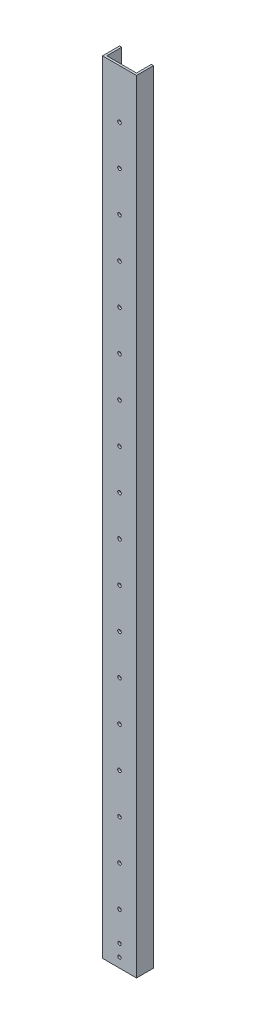
from build123d import *

# Parameters (mm, degrees)
BOSS_EXTRUDE1_DEPTH = 1168.4
CUT_EXTRUDE1_REACH  = 27.4
SKETCH2_R           = 2.667
CUT_EXTRUDE2_REACH  = 27.4
SKETCH3_R           = 2.5527
CUT_EXTRUDE3_REACH  = 52.8
SKETCH4_R           = 2.667


with BuildPart() as part:
    # Sketch1 → Boss-Extrude1 (new body)
    with BuildSketch(Plane(origin=(0, 0, 0), x_dir=(1, 0, 0), z_dir=(0, 1, 0))):
        Polygon((3.175, 3.175), (3.175, 25.4), (0, 25.4), (0, 0), (50.8, 0), (50.8, 25.4), (47.625, 25.4), (47.625, 3.175), align=None)
    extrude(amount=BOSS_EXTRUDE1_DEPTH)

    # Sketch2 → Cut-Extrude1 (cut, up to next)
    with BuildSketch(Plane.XY, mode=Mode.PRIVATE) as cut_extrude1_sk1:
        with Locations((25.4, 76.2)):
            Circle(SKETCH2_R)
    cut_extrude1_tool1 = extrude(cut_extrude1_sk1.sketch, amount=-CUT_EXTRUDE1_REACH, mode=Mode.PRIVATE) & part.part
    add(cut_extrude1_tool1.solids().sort_by_distance((25.4, 76.2, 0))[0], mode=Mode.SUBTRACT)
    # Sketch2 → Cut-Extrude1 (cut, up to next)
    with BuildSketch(Plane.XY, mode=Mode.PRIVATE) as cut_extrude1_sk2:
        with Locations((25.4, 136.144)):
            Circle(SKETCH2_R)
    cut_extrude1_tool2 = extrude(cut_extrude1_sk2.sketch, amount=-CUT_EXTRUDE1_REACH, mode=Mode.PRIVATE) & part.part
    add(cut_extrude1_tool2.solids().sort_by_distance((25.4, 136.144, 0))[0], mode=Mode.SUBTRACT)
    # Sketch2 → Cut-Extrude1 (cut, up to next)
    with BuildSketch(Plane.XY, mode=Mode.PRIVATE) as cut_extrude1_sk3:
        with Locations((25.4, 196.088)):
            Circle(SKETCH2_R)
    cut_extrude1_tool3 = extrude(cut_extrude1_sk3.sketch, amount=-CUT_EXTRUDE1_REACH, mode=Mode.PRIVATE) & part.part
    add(cut_extrude1_tool3.solids().sort_by_distance((25.4, 196.088, 0))[0], mode=Mode.SUBTRACT)
    # Sketch2 → Cut-Extrude1 (cut, up to next)
    with BuildSketch(Plane.XY, mode=Mode.PRIVATE) as cut_extrude1_sk4:
        with Locations((25.4, 256.032)):
            Circle(SKETCH2_R)
    cut_extrude1_tool4 = extrude(cut_extrude1_sk4.sketch, amount=-CUT_EXTRUDE1_REACH, mode=Mode.PRIVATE) & part.part
    add(cut_extrude1_tool4.solids().sort_by_distance((25.4, 256.032, 0))[0], mode=Mode.SUBTRACT)
    # Sketch2 → Cut-Extrude1 (cut, up to next)
    with BuildSketch(Plane.XY, mode=Mode.PRIVATE) as cut_extrude1_sk5:
        with Locations((25.4, 315.976)):
            Circle(SKETCH2_R)
    cut_extrude1_tool5 = extrude(cut_extrude1_sk5.sketch, amount=-CUT_EXTRUDE1_REACH, mode=Mode.PRIVATE) & part.part
    add(cut_extrude1_tool5.solids().sort_by_distance((25.4, 315.976, 0))[0], mode=Mode.SUBTRACT)
    # Sketch2 → Cut-Extrude1 (cut, up to next)
    with BuildSketch(Plane.XY, mode=Mode.PRIVATE) as cut_extrude1_sk6:
        with Locations((25.4, 375.92)):
            Circle(SKETCH2_R)
    cut_extrude1_tool6 = extrude(cut_extrude1_sk6.sketch, amount=-CUT_EXTRUDE1_REACH, mode=Mode.PRIVATE) & part.part
    add(cut_extrude1_tool6.solids().sort_by_distance((25.4, 375.92, 0))[0], mode=Mode.SUBTRACT)
    # Sketch2 → Cut-Extrude1 (cut, up to next)
    with BuildSketch(Plane.XY, mode=Mode.PRIVATE) as cut_extrude1_sk7:
        with Locations((25.4, 435.864)):
            Circle(SKETCH2_R)
    cut_extrude1_tool7 = extrude(cut_extrude1_sk7.sketch, amount=-CUT_EXTRUDE1_REACH, mode=Mode.PRIVATE) & part.part
    add(cut_extrude1_tool7.solids().sort_by_distance((25.4, 435.864, 0))[0], mode=Mode.SUBTRACT)
    # Sketch2 → Cut-Extrude1 (cut, up to next)
    with BuildSketch(Plane.XY, mode=Mode.PRIVATE) as cut_extrude1_sk8:
        with Locations((25.4, 495.808)):
            Circle(SKETCH2_R)
    cut_extrude1_tool8 = extrude(cut_extrude1_sk8.sketch, amount=-CUT_EXTRUDE1_REACH, mode=Mode.PRIVATE) & part.part
    add(cut_extrude1_tool8.solids().sort_by_distance((25.4, 495.808, 0))[0], mode=Mode.SUBTRACT)
    # Sketch2 → Cut-Extrude1 (cut, up to next)
    with BuildSketch(Plane.XY, mode=Mode.PRIVATE) as cut_extrude1_sk9:
        with Locations((25.4, 555.752)):
            Circle(SKETCH2_R)
    cut_extrude1_tool9 = extrude(cut_extrude1_sk9.sketch, amount=-CUT_EXTRUDE1_REACH, mode=Mode.PRIVATE) & part.part
    add(cut_extrude1_tool9.solids().sort_by_distance((25.4, 555.752, 0))[0], mode=Mode.SUBTRACT)
    # Sketch2 → Cut-Extrude1 (cut, up to next)
    with BuildSketch(Plane.XY, mode=Mode.PRIVATE) as cut_extrude1_sk10:
        with Locations((25.4, 615.696)):
            Circle(SKETCH2_R)
    cut_extrude1_tool10 = extrude(cut_extrude1_sk10.sketch, amount=-CUT_EXTRUDE1_REACH, mode=Mode.PRIVATE) & part.part
    add(cut_extrude1_tool10.solids().sort_by_distance((25.4, 615.696, 0))[0], mode=Mode.SUBTRACT)
    # Sketch2 → Cut-Extrude1 (cut, up to next)
    with BuildSketch(Plane.XY, mode=Mode.PRIVATE) as cut_extrude1_sk11:
        with Locations((25.4, 675.64)):
            Circle(SKETCH2_R)
    cut_extrude1_tool11 = extrude(cut_extrude1_sk11.sketch, amount=-CUT_EXTRUDE1_REACH, mode=Mode.PRIVATE) & part.part
    add(cut_extrude1_tool11.solids().sort_by_distance((25.4, 675.64, 0))[0], mode=Mode.SUBTRACT)
    # Sketch2 → Cut-Extrude1 (cut, up to next)
    with BuildSketch(Plane.XY, mode=Mode.PRIVATE) as cut_extrude1_sk12:
        with Locations((25.4, 735.584)):
            Circle(SKETCH2_R)
    cut_extrude1_tool12 = extrude(cut_extrude1_sk12.sketch, amount=-CUT_EXTRUDE1_REACH, mode=Mode.PRIVATE) & part.part
    add(cut_extrude1_tool12.solids().sort_by_distance((25.4, 735.584, 0))[0], mode=Mode.SUBTRACT)
    # Sketch2 → Cut-Extrude1 (cut, up to next)
    with BuildSketch(Plane.XY, mode=Mode.PRIVATE) as cut_extrude1_sk13:
        with Locations((25.4, 795.528)):
            Circle(SKETCH2_R)
    cut_extrude1_tool13 = extrude(cut_extrude1_sk13.sketch, amount=-CUT_EXTRUDE1_REACH, mode=Mode.PRIVATE) & part.part
    add(cut_extrude1_tool13.solids().sort_by_distance((25.4, 795.528, 0))[0], mode=Mode.SUBTRACT)
    # Sketch2 → Cut-Extrude1 (cut, up to next)
    with BuildSketch(Plane.XY, mode=Mode.PRIVATE) as cut_extrude1_sk14:
        with Locations((25.4, 855.472)):
            Circle(SKETCH2_R)
    cut_extrude1_tool14 = extrude(cut_extrude1_sk14.sketch, amount=-CUT_EXTRUDE1_REACH, mode=Mode.PRIVATE) & part.part
    add(cut_extrude1_tool14.solids().sort_by_distance((25.4, 855.472, 0))[0], mode=Mode.SUBTRACT)
    # Sketch2 → Cut-Extrude1 (cut, up to next)
    with BuildSketch(Plane.XY, mode=Mode.PRIVATE) as cut_extrude1_sk15:
        with Locations((25.4, 915.416)):
            Circle(SKETCH2_R)
    cut_extrude1_tool15 = extrude(cut_extrude1_sk15.sketch, amount=-CUT_EXTRUDE1_REACH, mode=Mode.PRIVATE) & part.part
    add(cut_extrude1_tool15.solids().sort_by_distance((25.4, 915.416, 0))[0], mode=Mode.SUBTRACT)
    # Sketch2 → Cut-Extrude1 (cut, up to next)
    with BuildSketch(Plane.XY, mode=Mode.PRIVATE) as cut_extrude1_sk16:
        with Locations((25.4, 975.36)):
            Circle(SKETCH2_R)
    cut_extrude1_tool16 = extrude(cut_extrude1_sk16.sketch, amount=-CUT_EXTRUDE1_REACH, mode=Mode.PRIVATE) & part.part
    add(cut_extrude1_tool16.solids().sort_by_distance((25.4, 975.36, 0))[0], mode=Mode.SUBTRACT)
    # Sketch2 → Cut-Extrude1 (cut, up to next)
    with BuildSketch(Plane.XY, mode=Mode.PRIVATE) as cut_extrude1_sk17:
        with Locations((25.4, 1035.304)):
            Circle(SKETCH2_R)
    cut_extrude1_tool17 = extrude(cut_extrude1_sk17.sketch, amount=-CUT_EXTRUDE1_REACH, mode=Mode.PRIVATE) & part.part
    add(cut_extrude1_tool17.solids().sort_by_distance((25.4, 1035.304, 0))[0], mode=Mode.SUBTRACT)
    # Sketch2 → Cut-Extrude1 (cut, up to next)
    with BuildSketch(Plane.XY, mode=Mode.PRIVATE) as cut_extrude1_sk18:
        with Locations((25.4, 1095.248)):
            Circle(SKETCH2_R)
    cut_extrude1_tool18 = extrude(cut_extrude1_sk18.sketch, amount=-CUT_EXTRUDE1_REACH, mode=Mode.PRIVATE) & part.part
    add(cut_extrude1_tool18.solids().sort_by_distance((25.4, 1095.248, 0))[0], mode=Mode.SUBTRACT)

    # Sketch3 → Cut-Extrude2 (cut, up to next)
    with BuildSketch(Plane.XY, mode=Mode.PRIVATE) as cut_extrude2_sk1:
        with Locations((25.4, 32.131)):
            Circle(SKETCH3_R)
    cut_extrude2_tool1 = extrude(cut_extrude2_sk1.sketch, amount=-CUT_EXTRUDE2_REACH, mode=Mode.PRIVATE) & part.part
    add(cut_extrude2_tool1.solids().sort_by_distance((25.4, 32.131, 0))[0], mode=Mode.SUBTRACT)
    # Sketch3 → Cut-Extrude2 (cut, up to next)
    with BuildSketch(Plane.XY, mode=Mode.PRIVATE) as cut_extrude2_sk2:
        with Locations((25.4, 14.2875)):
            Circle(SKETCH3_R)
    cut_extrude2_tool2 = extrude(cut_extrude2_sk2.sketch, amount=-CUT_EXTRUDE2_REACH, mode=Mode.PRIVATE) & part.part
    add(cut_extrude2_tool2.solids().sort_by_distance((25.4, 14.2875, 0))[0], mode=Mode.SUBTRACT)

    # Sketch4 → Cut-Extrude3 (cut, up to next)
    with BuildSketch(Plane.ZY, mode=Mode.PRIVATE) as cut_extrude3_sk1:
        with Locations((-19.05, 76.2)):
            Circle(SKETCH4_R)
    cut_extrude3_tool1 = extrude(cut_extrude3_sk1.sketch, amount=-CUT_EXTRUDE3_REACH, mode=Mode.PRIVATE) & part.part
    add(cut_extrude3_tool1.solids().sort_by_distance((0, 76.2, -19.05))[0], mode=Mode.SUBTRACT)
    # Sketch4 → Cut-Extrude3 (cut, up to next)
    with BuildSketch(Plane.ZY, mode=Mode.PRIVATE) as cut_extrude3_sk2:
        with Locations((-19.05, 136.144)):
            Circle(SKETCH4_R)
    cut_extrude3_tool2 = extrude(cut_extrude3_sk2.sketch, amount=-CUT_EXTRUDE3_REACH, mode=Mode.PRIVATE) & part.part
    add(cut_extrude3_tool2.solids().sort_by_distance((0, 136.144, -19.05))[0], mode=Mode.SUBTRACT)
    # Sketch4 → Cut-Extrude3 (cut, up to next)
    with BuildSketch(Plane.ZY, mode=Mode.PRIVATE) as cut_extrude3_sk3:
        with Locations((-19.05, 196.088)):
            Circle(SKETCH4_R)
    cut_extrude3_tool3 = extrude(cut_extrude3_sk3.sketch, amount=-CUT_EXTRUDE3_REACH, mode=Mode.PRIVATE) & part.part
    add(cut_extrude3_tool3.solids().sort_by_distance((0, 196.088, -19.05))[0], mode=Mode.SUBTRACT)
    # Sketch4 → Cut-Extrude3 (cut, up to next)
    with BuildSketch(Plane.ZY, mode=Mode.PRIVATE) as cut_extrude3_sk4:
        with Locations((-19.05, 256.032)):
            Circle(SKETCH4_R)
    cut_extrude3_tool4 = extrude(cut_extrude3_sk4.sketch, amount=-CUT_EXTRUDE3_REACH, mode=Mode.PRIVATE) & part.part
    add(cut_extrude3_tool4.solids().sort_by_distance((0, 256.032, -19.05))[0], mode=Mode.SUBTRACT)
    # Sketch4 → Cut-Extrude3 (cut, up to next)
    with BuildSketch(Plane.ZY, mode=Mode.PRIVATE) as cut_extrude3_sk5:
        with Locations((-19.05, 315.976)):
            Circle(SKETCH4_R)
    cut_extrude3_tool5 = extrude(cut_extrude3_sk5.sketch, amount=-CUT_EXTRUDE3_REACH, mode=Mode.PRIVATE) & part.part
    add(cut_extrude3_tool5.solids().sort_by_distance((0, 315.976, -19.05))[0], mode=Mode.SUBTRACT)
    # Sketch4 → Cut-Extrude3 (cut, up to next)
    with BuildSketch(Plane.ZY, mode=Mode.PRIVATE) as cut_extrude3_sk6:
        with Locations((-19.05, 375.92)):
            Circle(SKETCH4_R)
    cut_extrude3_tool6 = extrude(cut_extrude3_sk6.sketch, amount=-CUT_EXTRUDE3_REACH, mode=Mode.PRIVATE) & part.part
    add(cut_extrude3_tool6.solids().sort_by_distance((0, 375.92, -19.05))[0], mode=Mode.SUBTRACT)
    # Sketch4 → Cut-Extrude3 (cut, up to next)
    with BuildSketch(Plane.ZY, mode=Mode.PRIVATE) as cut_extrude3_sk7:
        with Locations((-19.05, 435.864)):
            Circle(SKETCH4_R)
    cut_extrude3_tool7 = extrude(cut_extrude3_sk7.sketch, amount=-CUT_EXTRUDE3_REACH, mode=Mode.PRIVATE) & part.part
    add(cut_extrude3_tool7.solids().sort_by_distance((0, 435.864, -19.05))[0], mode=Mode.SUBTRACT)
    # Sketch4 → Cut-Extrude3 (cut, up to next)
    with BuildSketch(Plane.ZY, mode=Mode.PRIVATE) as cut_extrude3_sk8:
        with Locations((-19.05, 495.808)):
            Circle(SKETCH4_R)
    cut_extrude3_tool8 = extrude(cut_extrude3_sk8.sketch, amount=-CUT_EXTRUDE3_REACH, mode=Mode.PRIVATE) & part.part
    add(cut_extrude3_tool8.solids().sort_by_distance((0, 495.808, -19.05))[0], mode=Mode.SUBTRACT)
    # Sketch4 → Cut-Extrude3 (cut, up to next)
    with BuildSketch(Plane.ZY, mode=Mode.PRIVATE) as cut_extrude3_sk9:
        with Locations((-19.05, 555.752)):
            Circle(SKETCH4_R)
    cut_extrude3_tool9 = extrude(cut_extrude3_sk9.sketch, amount=-CUT_EXTRUDE3_REACH, mode=Mode.PRIVATE) & part.part
    add(cut_extrude3_tool9.solids().sort_by_distance((0, 555.752, -19.05))[0], mode=Mode.SUBTRACT)
    # Sketch4 → Cut-Extrude3 (cut, up to next)
    with BuildSketch(Plane.ZY, mode=Mode.PRIVATE) as cut_extrude3_sk10:
        with Locations((-19.05, 615.696)):
            Circle(SKETCH4_R)
    cut_extrude3_tool10 = extrude(cut_extrude3_sk10.sketch, amount=-CUT_EXTRUDE3_REACH, mode=Mode.PRIVATE) & part.part
    add(cut_extrude3_tool10.solids().sort_by_distance((0, 615.696, -19.05))[0], mode=Mode.SUBTRACT)
    # Sketch4 → Cut-Extrude3 (cut, up to next)
    with BuildSketch(Plane.ZY, mode=Mode.PRIVATE) as cut_extrude3_sk11:
        with Locations((-19.05, 675.64)):
            Circle(SKETCH4_R)
    cut_extrude3_tool11 = extrude(cut_extrude3_sk11.sketch, amount=-CUT_EXTRUDE3_REACH, mode=Mode.PRIVATE) & part.part
    add(cut_extrude3_tool11.solids().sort_by_distance((0, 675.64, -19.05))[0], mode=Mode.SUBTRACT)
    # Sketch4 → Cut-Extrude3 (cut, up to next)
    with BuildSketch(Plane.ZY, mode=Mode.PRIVATE) as cut_extrude3_sk12:
        with Locations((-19.05, 735.584)):
            Circle(SKETCH4_R)
    cut_extrude3_tool12 = extrude(cut_extrude3_sk12.sketch, amount=-CUT_EXTRUDE3_REACH, mode=Mode.PRIVATE) & part.part
    add(cut_extrude3_tool12.solids().sort_by_distance((0, 735.584, -19.05))[0], mode=Mode.SUBTRACT)
    # Sketch4 → Cut-Extrude3 (cut, up to next)
    with BuildSketch(Plane.ZY, mode=Mode.PRIVATE) as cut_extrude3_sk13:
        with Locations((-19.05, 795.528)):
            Circle(SKETCH4_R)
    cut_extrude3_tool13 = extrude(cut_extrude3_sk13.sketch, amount=-CUT_EXTRUDE3_REACH, mode=Mode.PRIVATE) & part.part
    add(cut_extrude3_tool13.solids().sort_by_distance((0, 795.528, -19.05))[0], mode=Mode.SUBTRACT)
    # Sketch4 → Cut-Extrude3 (cut, up to next)
    with BuildSketch(Plane.ZY, mode=Mode.PRIVATE) as cut_extrude3_sk14:
        with Locations((-19.05, 855.472)):
            Circle(SKETCH4_R)
    cut_extrude3_tool14 = extrude(cut_extrude3_sk14.sketch, amount=-CUT_EXTRUDE3_REACH, mode=Mode.PRIVATE) & part.part
    add(cut_extrude3_tool14.solids().sort_by_distance((0, 855.472, -19.05))[0], mode=Mode.SUBTRACT)
    # Sketch4 → Cut-Extrude3 (cut, up to next)
    with BuildSketch(Plane.ZY, mode=Mode.PRIVATE) as cut_extrude3_sk15:
        with Locations((-19.05, 915.416)):
            Circle(SKETCH4_R)
    cut_extrude3_tool15 = extrude(cut_extrude3_sk15.sketch, amount=-CUT_EXTRUDE3_REACH, mode=Mode.PRIVATE) & part.part
    add(cut_extrude3_tool15.solids().sort_by_distance((0, 915.416, -19.05))[0], mode=Mode.SUBTRACT)
    # Sketch4 → Cut-Extrude3 (cut, up to next)
    with BuildSketch(Plane.ZY, mode=Mode.PRIVATE) as cut_extrude3_sk16:
        with Locations((-19.05, 975.36)):
            Circle(SKETCH4_R)
    cut_extrude3_tool16 = extrude(cut_extrude3_sk16.sketch, amount=-CUT_EXTRUDE3_REACH, mode=Mode.PRIVATE) & part.part
    add(cut_extrude3_tool16.solids().sort_by_distance((0, 975.36, -19.05))[0], mode=Mode.SUBTRACT)
    # Sketch4 → Cut-Extrude3 (cut, up to next)
    with BuildSketch(Plane.ZY, mode=Mode.PRIVATE) as cut_extrude3_sk17:
        with Locations((-19.05, 1035.304)):
            Circle(SKETCH4_R)
    cut_extrude3_tool17 = extrude(cut_extrude3_sk17.sketch, amount=-CUT_EXTRUDE3_REACH, mode=Mode.PRIVATE) & part.part
    add(cut_extrude3_tool17.solids().sort_by_distance((0, 1035.304, -19.05))[0], mode=Mode.SUBTRACT)
    # Sketch4 → Cut-Extrude3 (cut, up to next)
    with BuildSketch(Plane.ZY, mode=Mode.PRIVATE) as cut_extrude3_sk18:
        with Locations((-19.05, 1095.248)):
            Circle(SKETCH4_R)
    cut_extrude3_tool18 = extrude(cut_extrude3_sk18.sketch, amount=-CUT_EXTRUDE3_REACH, mode=Mode.PRIVATE) & part.part
    add(cut_extrude3_tool18.solids().sort_by_distance((0, 1095.248, -19.05))[0], mode=Mode.SUBTRACT)


solid = part.part
